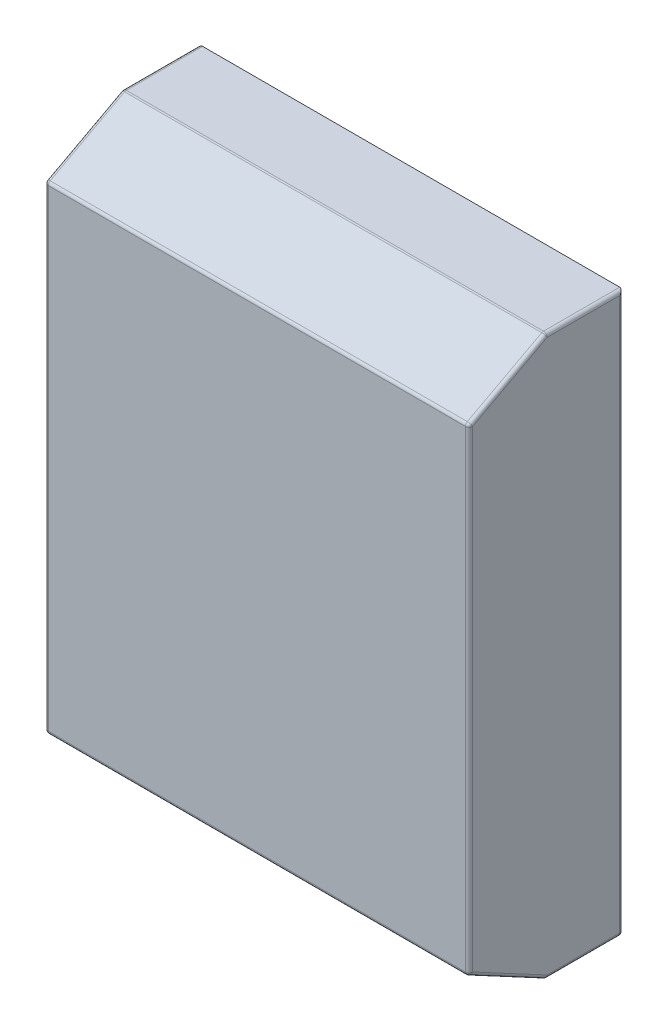
from build123d import *

# Parameters (mm, degrees)
SKETCH1_W           = 279.4
SKETCH1_H           = 368.3
BOSS_EXTRUDE1_DEPTH = 101.6
CUT_EXTRUDE2_DEPTH  = 343.662
CUT_EXTRUDE3_DEPTH  = 81.788
FILLET2_R           = 2.38


with BuildPart() as part:
    # Sketch1 → Boss-Extrude1 (new body)
    with BuildSketch(Plane.XY):
        with Locations((65.648946297, -14.210932476)):
            Rectangle(SKETCH1_W, SKETCH1_H)
    extrude(amount=BOSS_EXTRUDE1_DEPTH)

    # Sketch5 → Cut-Extrude2 (cut)
    with BuildSketch(Plane.ZY.offset(74.051053703)):
        Polygon((50.8, 169.939067524), (101.6, 142.764720342), (197.27126928, 191.743775141), (59.221541493, 225.542979991), align=None)
        Polygon((197.27126928, -220.165640093), (59.221541493, -253.964844943), (50.8, -198.360932476), (101.6, -171.186585294), align=None)
    extrude(amount=-CUT_EXTRUDE2_DEPTH, mode=Mode.SUBTRACT)

    # Sketch6 → Cut-Extrude3 (cut)
    with BuildSketch(Plane(origin=(0, -200.900932476, 0), x_dir=(-1, 0, 0), z_dir=(0, -1, 0))):
        with BuildLine():
            Line((47.465898878, -87.350896203), (-178.763791471, -87.350896203))
            ThreePointArc((-178.763791471, -87.350896203), (-188.288791471, -77.825896203), (-178.763791471, -68.300896203))
            Line((-178.763791471, -68.300896203), (47.465898878, -68.300896203))
            ThreePointArc((47.465898878, -68.300896203), (56.990898878, -77.825896203), (47.465898878, -87.350896203))
        make_face()
    extrude(amount=-CUT_EXTRUDE3_DEPTH, mode=Mode.SUBTRACT)

    # Fillet2
    fillet2_edges = [part.edges().sort_by_distance(p)[0] for p in [
        (-74.051053703, -14.210932476, 101.6),
        (205.348946297, -14.210932476, 101.6),
        (65.648946297, -171.186585294, 101.6),
        (65.648946297, 142.764720342, 101.6),
        (-74.051053703, 169.939067524, 25.4),
        (205.348946297, 169.939067524, 25.4),
        (205.348946297, -198.360932476, 25.4),
        (-74.051053703, -198.360932476, 25.4),
        (205.348946297, 156.351893933, 76.2),
        (-74.051053703, 156.351893933, 76.2),
        (65.648946297, 169.939067524, 50.8),
        (205.348946297, -184.773758885, 76.2),
        (65.648946297, -198.360932476, 50.8),
        (-74.051053703, -184.773758885, 76.2),
        (205.348946297, -14.210932476, 0),
        (65.648946297, -198.360932476, 0),
        (-74.051053703, -14.210932476, 0),
    ]]
    fillet(fillet2_edges, radius=FILLET2_R)


solid = part.part
